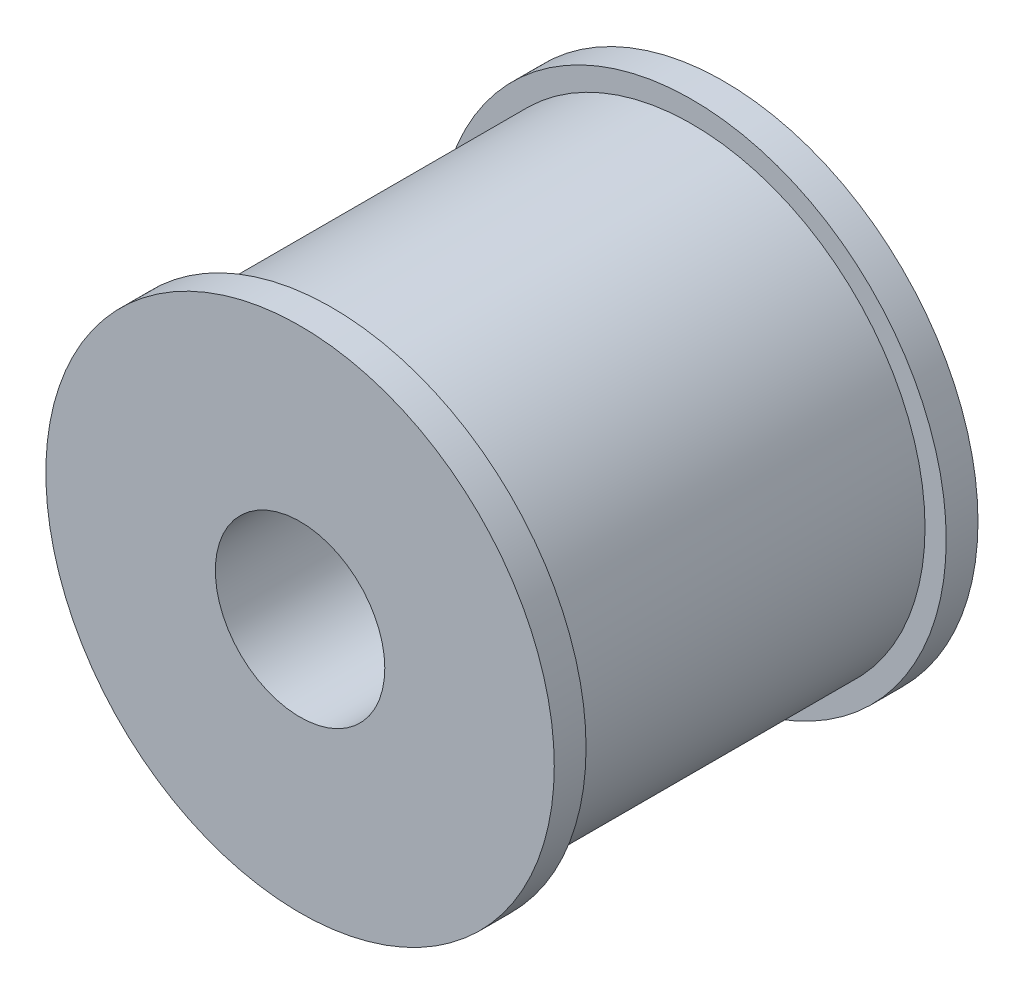
from build123d import *

# Parameters (mm, degrees)
SKETCH1_R           = 12
SKETCH1_R_2         = 4
BOSS_EXTRUDE1_DEPTH = 20
CUT_EXTRUDE1_START  = -1.5
SKETCH2_R           = 17.91123385
SKETCH2_R_2         = 11
CUT_EXTRUDE1_DEPTH  = 17


with BuildPart() as part:
    # Sketch1 → Boss-Extrude1 (new body)
    with BuildSketch(Plane.XY):
        Circle(SKETCH1_R)
        Circle(SKETCH1_R_2, mode=Mode.SUBTRACT)
    extrude(amount=BOSS_EXTRUDE1_DEPTH)

    # Sketch2 → Cut-Extrude1 (cut)
    with BuildSketch(Plane.XY.offset(20).offset(CUT_EXTRUDE1_START)):
        Circle(SKETCH2_R)
        Circle(SKETCH2_R_2, mode=Mode.SUBTRACT)
    extrude(amount=-CUT_EXTRUDE1_DEPTH, mode=Mode.SUBTRACT)


solid = part.part
